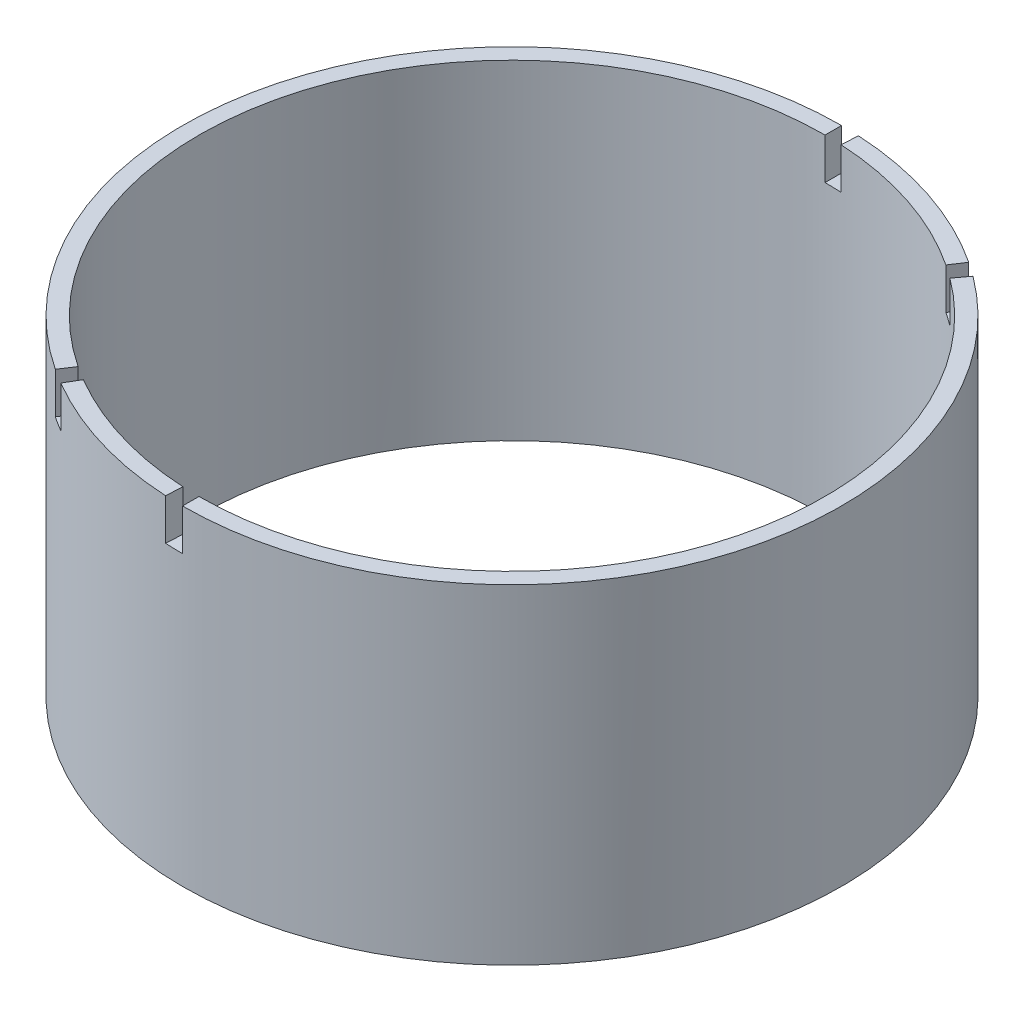
from build123d import *

# Parameters (mm, degrees)
ESQUISSE1_R      = 40
ESQUISSE1_R_2    = 38
EXTRUSION1_DEPTH = 40
EXTRUSION2_DEPTH = 5


with BuildPart() as part:
    # Esquisse1 → Extrusion1 (new body)
    with BuildSketch(Plane(origin=(0, 0, 0), x_dir=(1, 0, 0), z_dir=(0, 1, 0))):
        Circle(ESQUISSE1_R)
        Circle(ESQUISSE1_R_2, mode=Mode.SUBTRACT)
    extrude(amount=EXTRUSION1_DEPTH)

    # Esquisse2 → Extrusion2 (cut)
    with BuildSketch(Plane(origin=(0, 40, 0), x_dir=(1, 0, 0), z_dir=(0, 1, 0))):
        with BuildLine():
            Line((0, -40), (0, -38))
            ThreePointArc((0, -38), (-1.000346681, -37.986830699), (-2, -37.947331922))
            Line((-2, -37.947331922), (-2.105263158, -39.944559918))
            ThreePointArc((-2.105263158, -39.944559918), (-1.052996506, -39.986137577), (0, -40))
        make_face()
        with BuildLine():
            Line((0, 40), (0, 38))
            ThreePointArc((0, 38), (1.000346681, 37.986830699), (2, 37.947331922))
            Line((2, 37.947331922), (2.105263158, 39.944559918))
            ThreePointArc((2.105263158, 39.944559918), (1.052996506, 39.986137577), (0, 40))
        make_face()
        with BuildLine():
            Line((22.096109748, 33.343094247), (20.991304261, 31.675939535))
            ThreePointArc((20.991304261, 31.675939535), (21.817611901, 31.112566769), (22.628807775, 30.527644172))
            Line((22.628807775, 30.527644172), (23.819797658, 32.134362286))
            ThreePointArc((23.819797658, 32.134362286), (22.965907264, 32.750070283), (22.096109748, 33.343094247))
        make_face()
        with BuildLine():
            Line((-20.311213778, -34.459463067), (-19.295653089, -32.736489913))
            ThreePointArc((-19.295653089, -32.736489913), (-20.150457189, -32.217372256), (-20.991304261, -31.675939535))
            Line((-20.991304261, -31.675939535), (-22.096109748, -33.343094247))
            ThreePointArc((-22.096109748, -33.343094247), (-21.211007567, -33.913023427), (-20.311213778, -34.459463067))
        make_face()
    extrude(amount=-EXTRUSION2_DEPTH, mode=Mode.SUBTRACT)


solid = part.part
